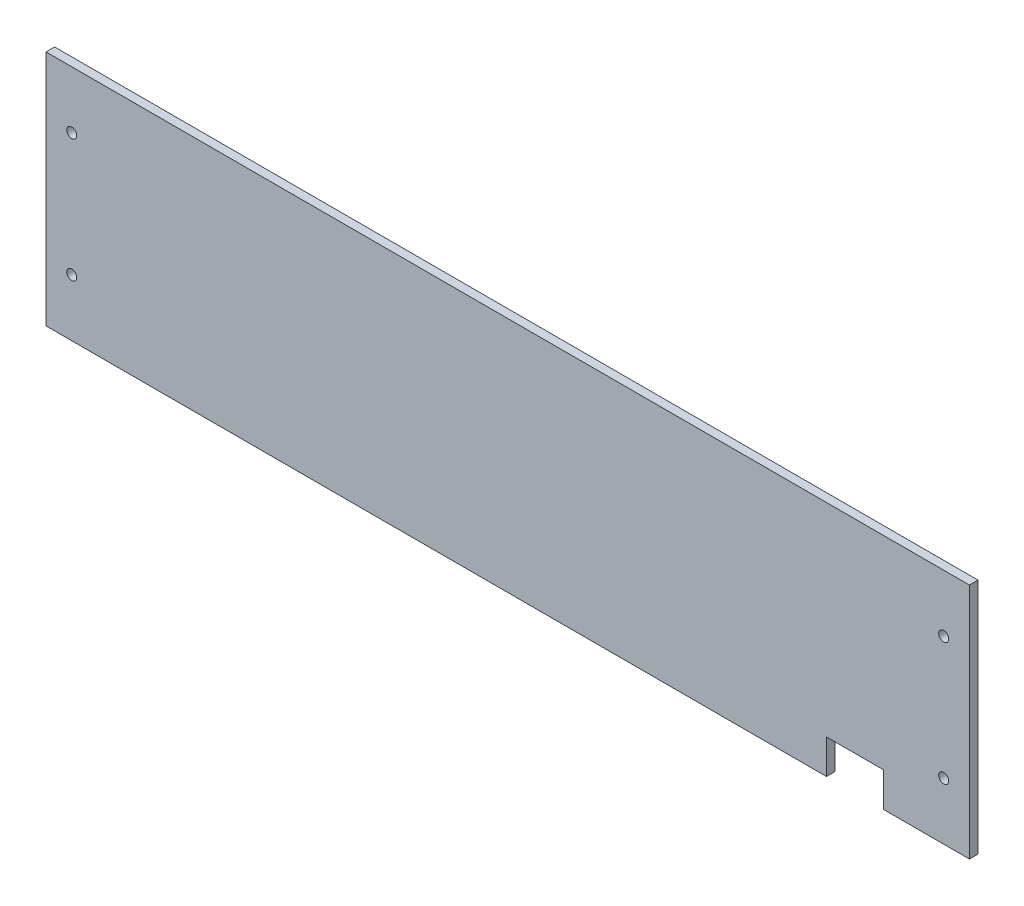
from build123d import *

# Parameters (mm, degrees)
SKETCH1_W           = 323
SKETCH1_H           = 83
BOSS_EXTRUDE1_DEPTH = 3
SKETCH2_W           = 20
SKETCH2_H           = 12
CUT_EXTRUDE1_DEPTH  = 10
SKETCH4_R           = 1.75
CUT_EXTRUDE2_DEPTH  = 4


with BuildPart() as part:
    # Sketch1 → Boss-Extrude1 (new body)
    with BuildSketch(Plane.XY):
        Rectangle(SKETCH1_W, SKETCH1_H)
    extrude(amount=BOSS_EXTRUDE1_DEPTH)

    # Sketch2 → Cut-Extrude1 (cut)
    with BuildSketch(Plane(origin=(0, 0, 0), x_dir=(-1, 0, 0), z_dir=(0, 0, -1))):
        with Locations((-121.5, -35.5)):
            Rectangle(SKETCH2_W, SKETCH2_H)
    extrude(amount=-CUT_EXTRUDE1_DEPTH, mode=Mode.SUBTRACT)

    # Sketch4 → Cut-Extrude2 (cut, through all)
    with BuildSketch(Plane(origin=(0, 0, 0), x_dir=(-1, 0, 0), z_dir=(0, 0, -1))):
        with Locations((152.5, -21.5)):
            Circle(SKETCH4_R)
        with Locations((-152.5, -21.5)):
            Circle(SKETCH4_R)
        with Locations((152.5, 21.5)):
            Circle(SKETCH4_R)
        with Locations((-152.5, 21.5)):
            Circle(SKETCH4_R)
    extrude(amount=-CUT_EXTRUDE2_DEPTH, mode=Mode.SUBTRACT)


solid = part.part
